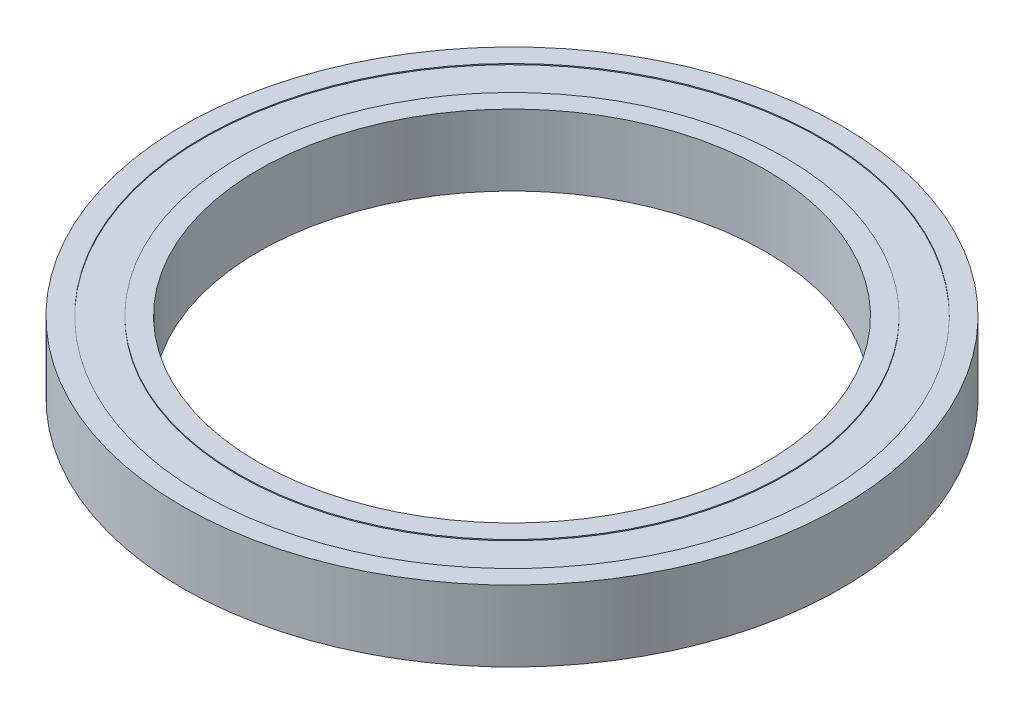
from build123d import *

# Parameters (mm, degrees)
SKETCH1_R             = 32.5
SKETCH1_R_2           = 30.5
BOSS_EXTRUDE1_DEPTH   = 3.5
SKETCH1_R_3           = 27
SKETCH1_R_4           = 25
BOSS_EXTRUDE1_2_DEPTH = 3.5
SKETCH1_3_R           = 30.5
SKETCH1_3_R_2         = 27
BOSS_EXTRUDE2_DEPTH   = 3.4


with BuildPart() as part:
    # Sketch1 → Boss-Extrude1 (new, symmetric)
    with BuildSketch(Plane(origin=(0, 0, 0), x_dir=(1, 0, 0), z_dir=(0, 1, 0))):
        Circle(SKETCH1_R)
        Circle(SKETCH1_R_2, mode=Mode.SUBTRACT)
    extrude(amount=BOSS_EXTRUDE1_DEPTH, both=True)



with BuildPart() as body_2:
    # Sketch1 → Boss-Extrude1 2 (new, symmetric)
    with BuildSketch(Plane(origin=(0, 0, 0), x_dir=(1, 0, 0), z_dir=(0, 1, 0))):
        Circle(SKETCH1_R_3)
        Circle(SKETCH1_R_4, mode=Mode.SUBTRACT)
    extrude(amount=BOSS_EXTRUDE1_2_DEPTH, both=True)


with BuildPart() as part_1:
    add(part.part)

    add(body_2.part)  # Boss-Extrude2 merges body 2
    # Sketch1_3 → Boss-Extrude2 (add, symmetric)
    with BuildSketch(Plane(origin=(0, 0, 0), x_dir=(1, 0, 0), z_dir=(0, 1, 0))):
        Circle(SKETCH1_3_R)
        Circle(SKETCH1_3_R_2, mode=Mode.SUBTRACT)
    extrude(amount=BOSS_EXTRUDE2_DEPTH, both=True)


solid = part_1.part
